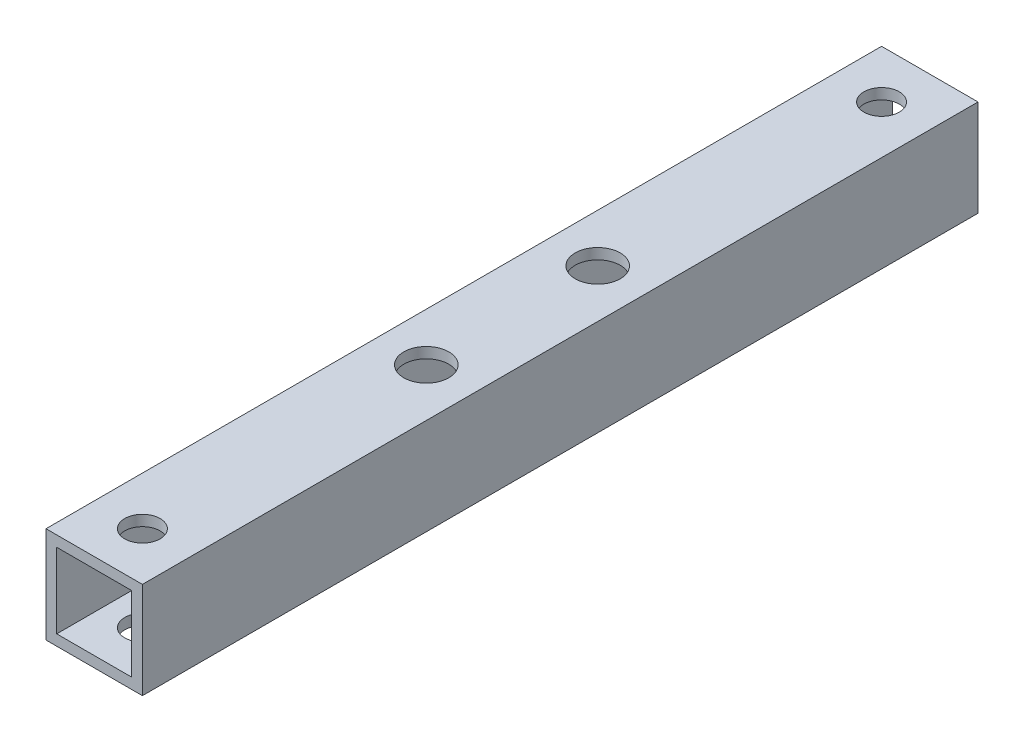
from build123d import *

# Parameters (mm, degrees)
SKETCH_1_W          = 9
SKETCH_1_H          = 9
EXTRUDE_1_DEPTH     = 78
SKETCH_2_W          = 7
SKETCH_2_H          = 7
CUT_EXTRUDE_1_DEPTH = 90
SKETCH_3_R          = 1.65
CUT_EXTRUDE_2_DEPTH = 75
SKETCH_4_R          = 2.1
CUT_EXTRUDE_3_DEPTH = 75


with BuildPart() as part:
    # ｽｹｯﾁ1 → ﾎﾞｽ - 押し出し1 (new body)
    with BuildSketch(Plane.XY):
        Rectangle(SKETCH_1_W, SKETCH_1_H)
    extrude(amount=EXTRUDE_1_DEPTH)

    # ｽｹｯﾁ2 → ｶｯﾄ - 押し出し1 (cut)
    with BuildSketch(Plane.XY.offset(78)):
        Rectangle(SKETCH_2_W, SKETCH_2_H)
    extrude(amount=-CUT_EXTRUDE_1_DEPTH, mode=Mode.SUBTRACT)

    # ｽｹｯﾁ3 → ｶｯﾄ - 押し出し2 (cut)
    with BuildSketch(Plane(origin=(0, 4.5, 0), x_dir=(1, 0, 0), z_dir=(0, 1, 0))):
        with Locations((0, -4.5)):
            Circle(SKETCH_3_R)
        with Locations((0, -73.5)):
            Circle(SKETCH_3_R)
    extrude(amount=-CUT_EXTRUDE_2_DEPTH, mode=Mode.SUBTRACT)

    # ｽｹｯﾁ4 → ｶｯﾄ - 押し出し3 (cut)
    with BuildSketch(Plane(origin=(0, 4.5, 0), x_dir=(1, 0, 0), z_dir=(0, 1, 0))):
        with Locations((0, -31)):
            Circle(SKETCH_4_R)
        with Locations((0, -47)):
            Circle(SKETCH_4_R)
    extrude(amount=-CUT_EXTRUDE_3_DEPTH, mode=Mode.SUBTRACT)


solid = part.part
